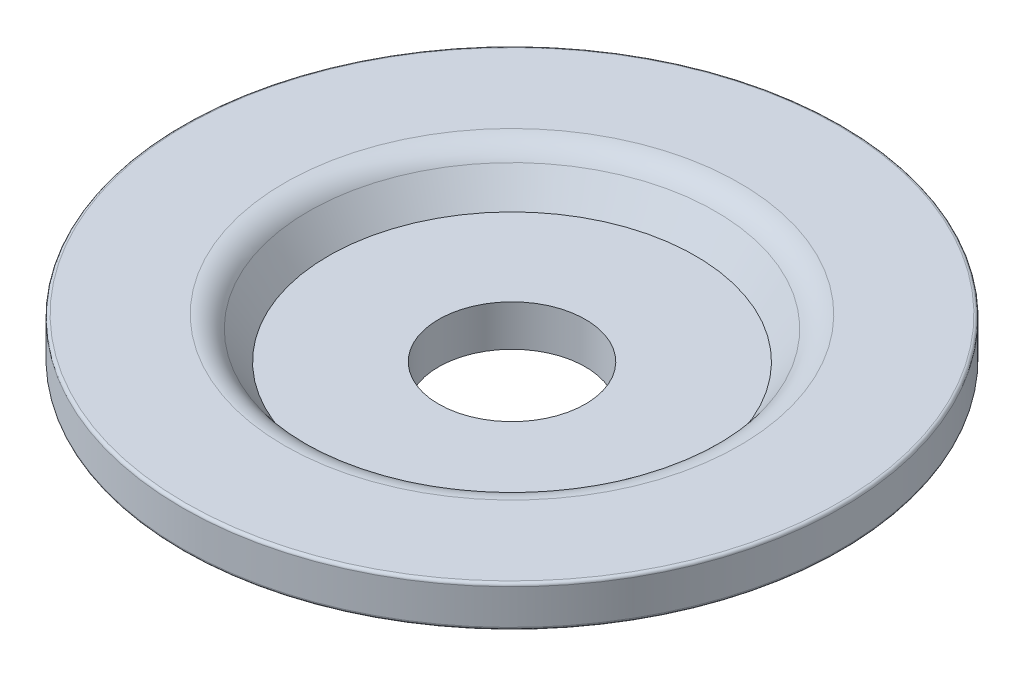
from build123d import *


with BuildPart() as part:
    # Sketch1 → Revolve1 (revolve)
    with BuildSketch(Plane.XY, mode=Mode.PRIVATE) as revolve1_sk:
        with BuildLine():
            Line((2.5, 0), (6.25, 0))
            Line((6.25, 0), (6.930508845, 0.973091831))
            ThreePointArc((6.930508845, 0.973091831), (7.287989086, 1.286874239), (7.75, 1.4))
            Line((7.75, 1.4), (11.125, 1.4))
            ThreePointArc((11.125, 1.4), (11.195710678, 1.370710678), (11.225, 1.3))
            Line((11.225, 1.3), (11.225, 0.1))
            ThreePointArc((11.225, 0.1), (11.195710678, 0.029289322), (11.125, 0))
            Line((11.125, 0), (7.958377194, 0))
            Line((7.958377194, 0), (7.427142434, -0.759637747))
            ThreePointArc((7.427142434, -0.759637747), (6.890922072, -1.230311358), (6.197905701, -1.4))
            Line((6.197905701, -1.4), (2.5, -1.4))
            Line((2.5, -1.4), (2.5, 0))
        make_face()
    revolve(revolve1_sk.sketch.rotate(Axis((0, 11.539064392, 0), (0, -1, 0)), 90), axis=Axis((0, 11.539064392, 0), (0, -1, 0)))


solid = part.part
